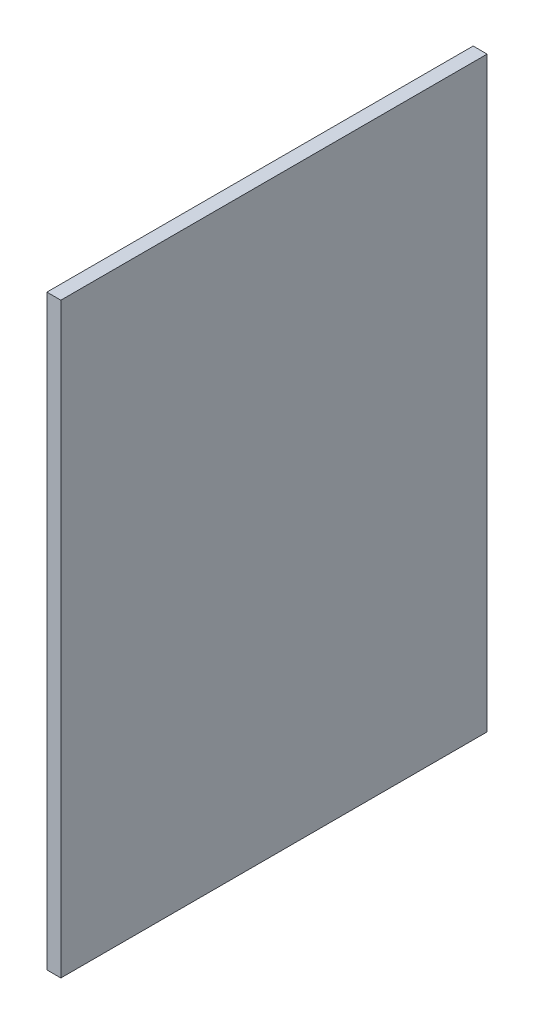
from build123d import *

# Parameters (mm, degrees)
SKETCH7_W           = 3.175
SKETCH7_H           = 96.8375
BOSS_EXTRUDE1_DEPTH = 66.675


with BuildPart() as part:
    # Sketch7 → Boss-Extrude1 (new body, symmetric)
    with BuildSketch(Plane(origin=(0, 0, 0), x_dir=(1, 0, 0), z_dir=(0, 1, 0))):
        with Locations((41.275, 124.61875)):
            Rectangle(SKETCH7_W, SKETCH7_H)
    extrude(amount=BOSS_EXTRUDE1_DEPTH, both=True)


solid = part.part
